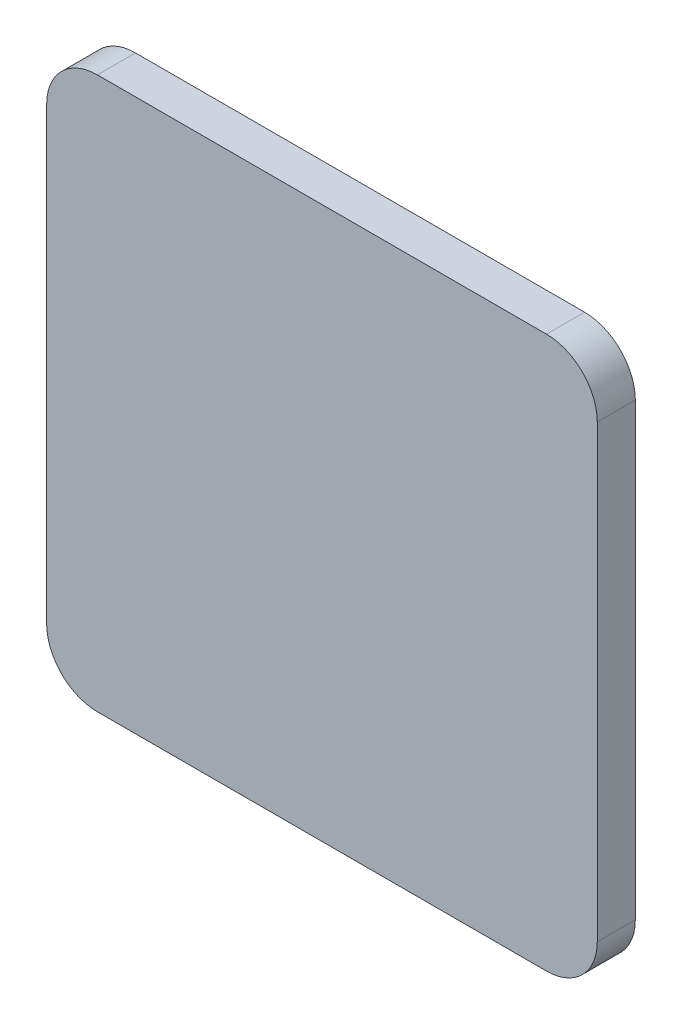
from build123d import *

# Parameters (mm, degrees)
SKETCH1_W           = 21.700247653
SKETCH1_H           = 21.740751921
BOSS_EXTRUDE1_DEPTH = 1.5
FILLET1_R           = 2


with BuildPart() as part:
    # Sketch1 → Boss-Extrude1 (new body)
    with BuildSketch(Plane.XY):
        with Locations((10.850123827, 10.870375961)):
            Rectangle(SKETCH1_W, SKETCH1_H)
    extrude(amount=BOSS_EXTRUDE1_DEPTH)

    # Fillet1
    fillet1_edges = [part.edges().sort_by_distance(p)[0] for p in [
        (0, 21.740751921, 0.75),
        (21.700247653, 21.740751921, 0.75),
        (21.700247653, 0, 0.75),
        (0, 0, 0.75),
    ]]
    fillet(fillet1_edges, radius=FILLET1_R)


solid = part.part
